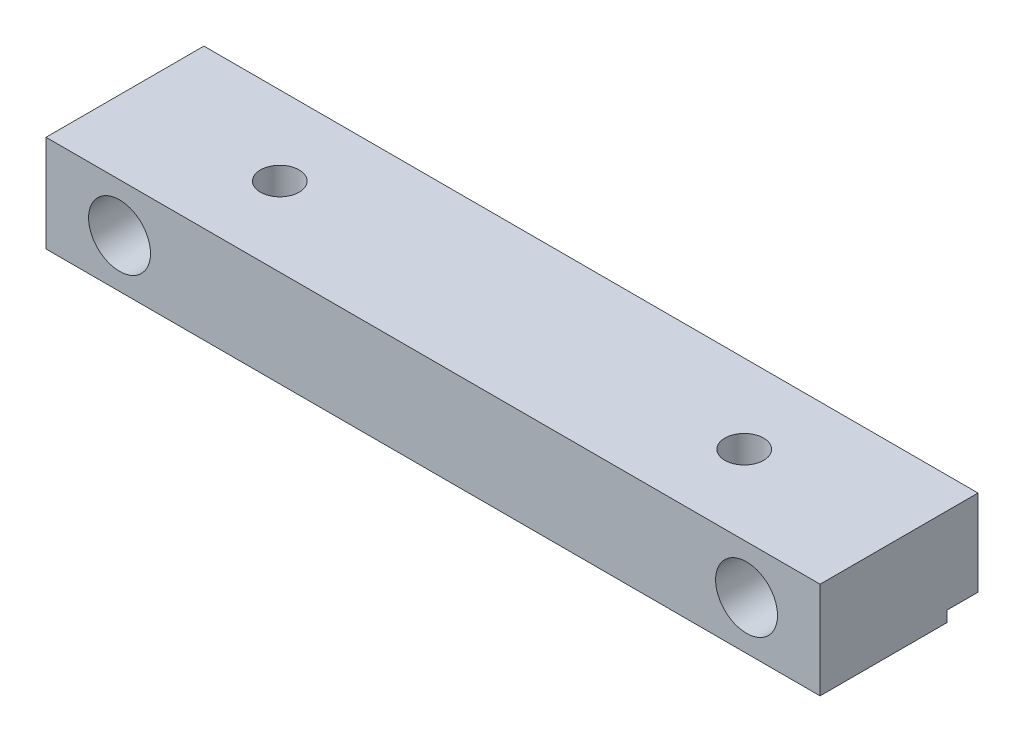
from build123d import *

# Parameters (mm, degrees)
SKETCH1_W                  = 50
SKETCH1_H                  = 10.2
BOSS_EXTRUDE1_DEPTH        = 6.25
F_4_0_4_DIAMETER_HOLE1_D   = 4
F_2_5_2_5_DIAMETER_HOLE1_D = 2.5
SKETCH6_W                  = 2
SKETCH6_H                  = 0.7
CUT_EXTRUDE1_DEPTH         = 51


with BuildPart() as part:
    # Sketch1 → Boss-Extrude1 (new body)
    with BuildSketch(Plane(origin=(0, 0, 0), x_dir=(1, 0, 0), z_dir=(0, 1, 0))):
        with Locations((25, 5.1)):
            Rectangle(SKETCH1_W, SKETCH1_H)
    extrude(amount=BOSS_EXTRUDE1_DEPTH)

    # Ø4.0 (4) Diameter Hole1 (through all)
    with Locations(Plane.XY):
        with Locations((4.75, 3.125), (45.25, 3.125)):
            Hole(F_4_0_4_DIAMETER_HOLE1_D / 2)

    # Ø2.5 (2.5) Diameter Hole1 (through all)
    with Locations(Plane(origin=(0, 6.25, 0), x_dir=(-1, 0, 0), z_dir=(0, 1, 0))):
        with Locations((-10, -5.1), (-40, -5.1)):
            Hole(F_2_5_2_5_DIAMETER_HOLE1_D / 2)

    # Sketch6 → Cut-Extrude1 (cut, through all)
    with BuildSketch(Plane(origin=(50, 0, 0), x_dir=(0, 0, -1), z_dir=(1, 0, 0))):
        with Locations((9.2, 0.35)):
            Rectangle(SKETCH6_W, SKETCH6_H)
    extrude(amount=-CUT_EXTRUDE1_DEPTH, mode=Mode.SUBTRACT)


solid = part.part
